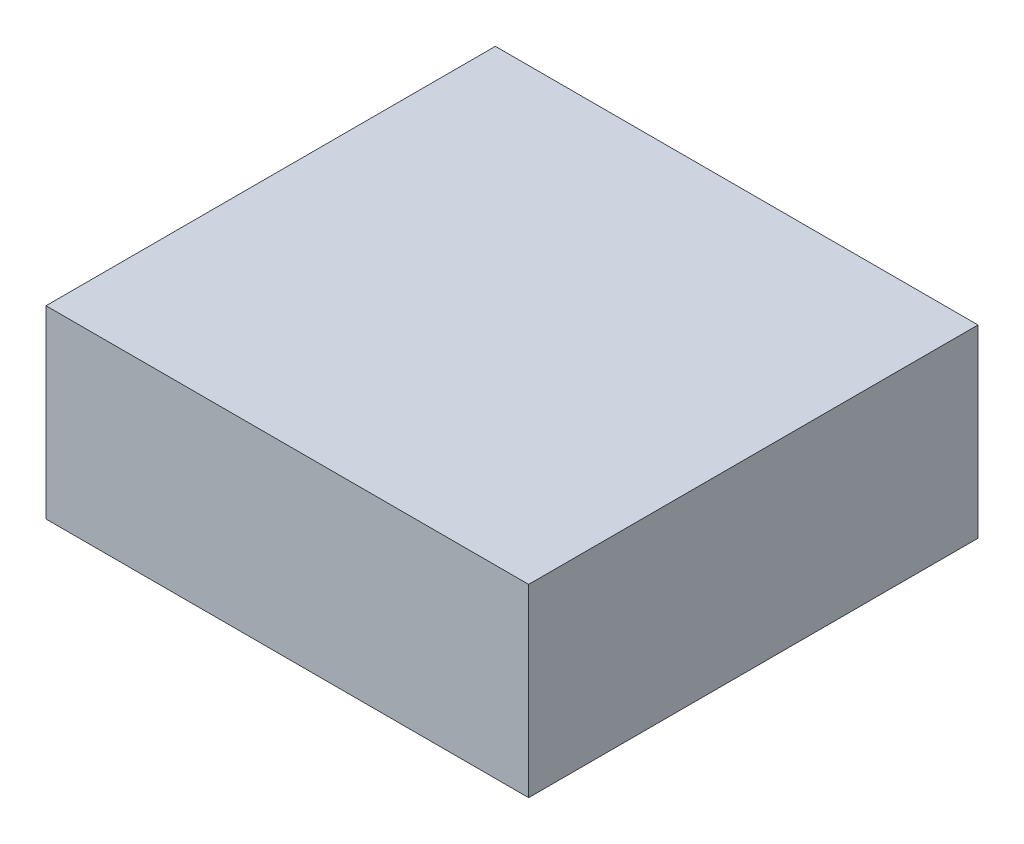
from build123d import *

# Parameters (mm, degrees)
SKETCH1_W           = 73.66
SKETCH1_H           = 68.58
BOSS_EXTRUDE1_DEPTH = 28.194
SKETCH2_W           = 60.96
SKETCH2_H           = 55.88
CUT_EXTRUDE1_DEPTH  = 21.844


with BuildPart() as part:
    # Sketch1 → Boss-Extrude1 (new body)
    with BuildSketch(Plane(origin=(0, 0, 0), x_dir=(1, 0, 0), z_dir=(0, 1, 0))):
        with Locations((-16.944230913, -20.491278483)):
            Rectangle(SKETCH1_W, SKETCH1_H)
    extrude(amount=BOSS_EXTRUDE1_DEPTH)

    # Sketch2 → Cut-Extrude1 (cut)
    with BuildSketch(Plane.XZ):
        with Locations((-16.944230913, 20.491278483)):
            Rectangle(SKETCH2_W, SKETCH2_H)
    extrude(amount=-CUT_EXTRUDE1_DEPTH, mode=Mode.SUBTRACT)


solid = part.part
